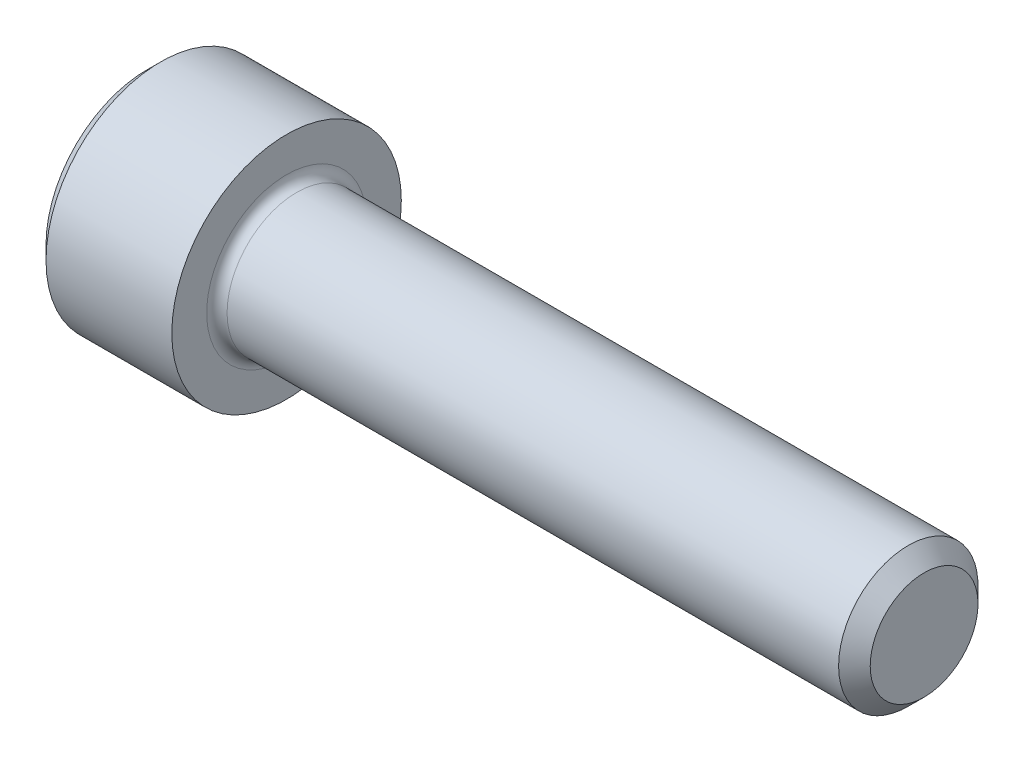
from build123d import *

# Parameters (mm, degrees)
FILLET1_R   = 0.3048
HEX_2_DEPTH = 1.9558


with BuildPart() as part:
    # BodySke → Base-Revolve (revolve)
    with BuildSketch(Plane.XY):
        Polygon((0, 0), (0, 3.0226), (0.4064, 3.429), (4.1656, 3.429), (4.1656, 2.0828), (22.74316, 2.0828), (23.2156, 1.61036), (23.2156, 0), align=None)
    revolve(axis=Axis((-31.75, 0, 0), (1, 0, 0)))

    # Fillet1
    fillet1_edges = [part.edges().sort_by_distance(p)[0] for p in [
        (4.1656, -2.0828, 0),
    ]]
    fillet(fillet1_edges, radius=FILLET1_R)

    # Sketch3 → Hex 2 (cut)
    with BuildSketch(Plane(origin=(0, 0, 0), x_dir=(0, 0.500000000000001, 0.866025403784438), z_dir=(-1, 0, 0))):
        Polygon((1.026528779, 1.778), (-1.026528779, 1.778), (-2.053057557, 0), (-1.026528779, -1.778), (1.026528779, -1.778), (2.053057557, 0), align=None)
    extrude(amount=-HEX_2_DEPTH, mode=Mode.SUBTRACT)


solid = part.part
